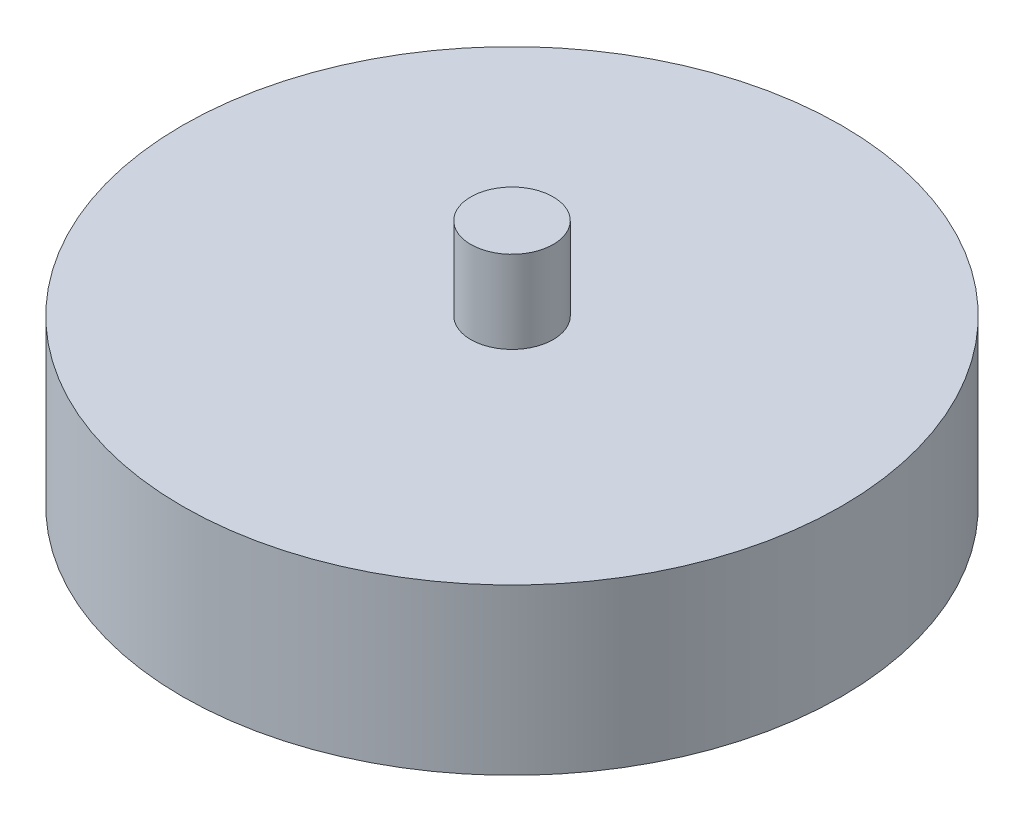
from build123d import *

# Parameters (mm, degrees)
SKETCH1_R           = 101.6
BOSS_EXTRUDE1_DEPTH = 50.8
SKETCH2_R           = 12.7
BOSS_EXTRUDE2_DEPTH = 25.4


with BuildPart() as part:
    # Sketch1 → Boss-Extrude1 (new body)
    with BuildSketch(Plane(origin=(0, 0, 0), x_dir=(1, 0, 0), z_dir=(0, 1, 0))):
        Circle(SKETCH1_R)
    extrude(amount=BOSS_EXTRUDE1_DEPTH)

    # Sketch2 → Boss-Extrude2 (add)
    with BuildSketch(Plane(origin=(0, 50.8, 0), x_dir=(1, 0, 0), z_dir=(0, 1, 0))):
        Circle(SKETCH2_R)
    extrude(amount=BOSS_EXTRUDE2_DEPTH)


solid = part.part
